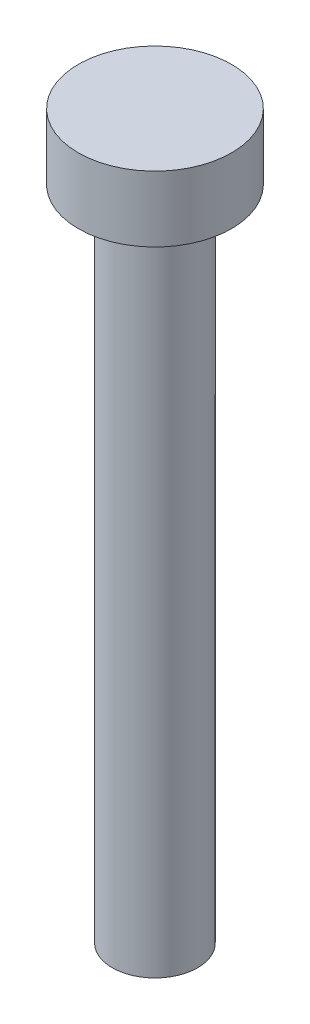
from build123d import *

# Parameters (mm, degrees)
SKETCH1_R           = 3.5
BOSS_EXTRUDE1_DEPTH = 3
SKETCH2_R           = 1.95
BOSS_EXTRUDE2_DEPTH = 30


with BuildPart() as part:
    # Sketch1 → Boss-Extrude1 (new body)
    with BuildSketch(Plane(origin=(0, 0, 0), x_dir=(1, 0, 0), z_dir=(0, 1, 0))):
        Circle(SKETCH1_R)
    extrude(amount=BOSS_EXTRUDE1_DEPTH)

    # Sketch2 → Boss-Extrude2 (add)
    with BuildSketch(Plane.XZ):
        Circle(SKETCH2_R)
    extrude(amount=BOSS_EXTRUDE2_DEPTH)


solid = part.part
